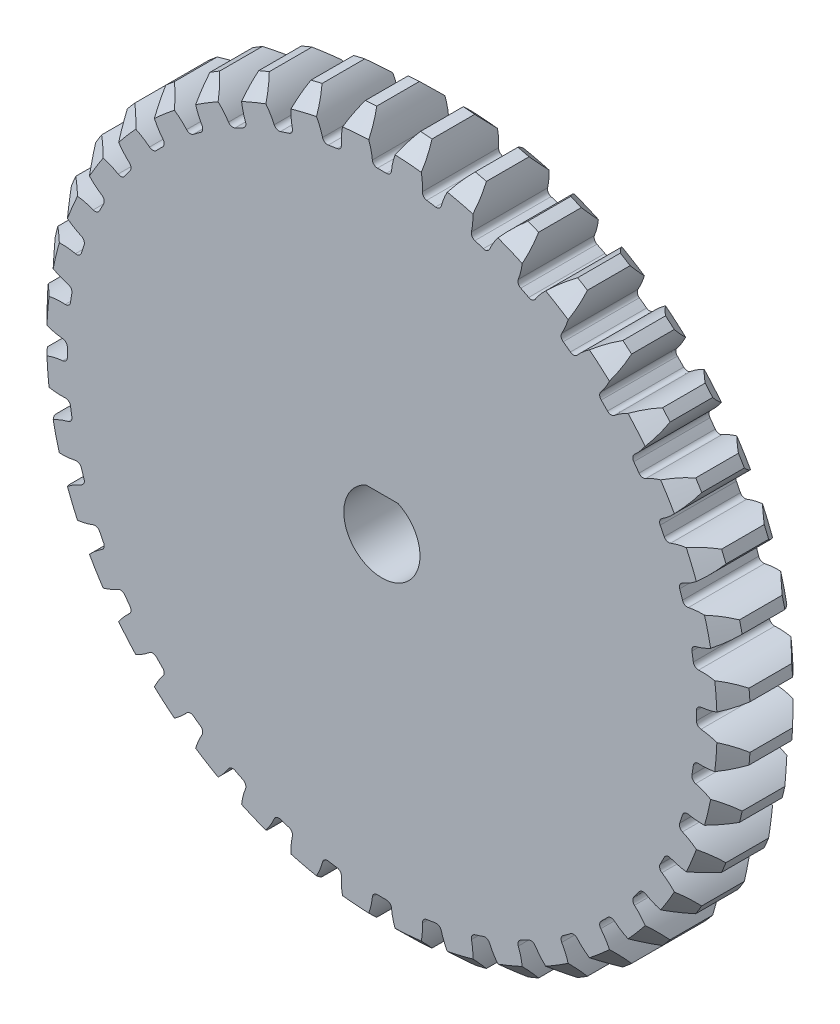
from build123d import *

# Parameters (mm, degrees)
SKETCH1_R                = 46.2
BOSS_EXTRUDE1_DEPTH      = 5
CUT_EXTRUDE1_DEPTH       = 66.527704065
FILLET1_R                = 0.66
CHAMFER1_SIZE            = 2.2
CIRPATTERN1_COUNT        = 40
FILLET1_OF_CIRPATTERN1_R = 0.66
CUT_EXTRUDE2_DEPTH       = 66.972376168
FILLET2_R                = 0.2
BOSS_EXTRUDE2_START      = -10
SKETCH5_R                = 10
BOSS_EXTRUDE2_DEPTH      = 19
SKETCH6_R                = 1.15
CUT_EXTRUDE3_DEPTH       = 67.695985001


with BuildPart() as part:
    # Sketch1 → Boss-Extrude1 (new, symmetric)
    with BuildSketch(Plane.XY):
        Circle(SKETCH1_R)
    extrude(amount=BOSS_EXTRUDE1_DEPTH, both=True)

    # Sketch2 → Cut-Extrude1 (cut, symmetric)
    with BuildSketch(Plane.XY):
        with BuildLine():
            ThreePointArc((2.874508928, 46.110489028), (1.67667641, 43.822688054), (1.213419035, 41.282170658))
            ThreePointArc((1.213419035, 41.282170658), (0, 41.3), (-1.213419035, 41.282170658))
            ThreePointArc((-1.213419035, 41.282170658), (-1.67667641, 43.822688054), (-2.874508928, 46.110489028))
            ThreePointArc((-2.874508928, 46.110489028), (0, 46.2), (2.874508928, 46.110489028))
        make_face()
    cut_extrude1 = extrude(amount=CUT_EXTRUDE1_DEPTH, both=True, mode=Mode.SUBTRACT)

    # Fillet1
    fillet1_edges = [part.edges().sort_by_distance(p)[0] for p in [
        (1.213419035, 41.282170658, 0),
        (-1.213419035, 41.282170658, 0),
    ]]
    fillet(fillet1_edges, radius=FILLET1_R)

    # Chamfer1
    chamfer1_edges = [part.edges().sort_by_distance(p)[0] for p in [
        (-31.635721009, -33.669290997, -5),
        (-31.635721009, -33.669290997, 5),
    ]]
    chamfer(chamfer1_edges, length=CHAMFER1_SIZE)

    # CirPattern1: Cut-Extrude1 ×40 about axis
    cirpattern1_axis = Axis((0, 0, 0), (0, 0, 1))
    for i in range(1, CIRPATTERN1_COUNT):
        add(cut_extrude1.rotate(cirpattern1_axis, i * 360 / CIRPATTERN1_COUNT), mode=Mode.SUBTRACT)

    # Fillet1 of CirPattern1
    fillet1_of_cirpattern1_edges = [part.edges().sort_by_distance(p)[0] for p in [
        (-5.25947445, 40.963739191, 0),
        (-7.656434116, 40.584098076, 0),
        (-11.602862218, 39.636644514, 0),
        (-13.910922378, 38.886710308, 0),
        (-17.660549011, 37.333564103, 0),
        (-19.822877564, 36.231802675, 0),
        (-23.283374475, 34.111207441, 0),
        (-25.246727716, 32.684747814, 0),
        (-28.332885987, 30.048919642, 0),
        (-30.048919642, 28.332885987, 0),
        (-32.684747814, 25.246727716, 0),
        (-34.111207441, 23.283374475, 0),
        (-36.231802675, 19.822877564, 0),
        (-37.333564103, 17.660549011, 0),
        (-38.886710308, 13.910922378, 0),
        (-39.636644514, 11.602862218, 0),
        (-40.584098076, 7.656434116, 0),
        (-40.963739191, 5.25947445, 0),
        (-41.282170658, 1.213419035, 0),
        (-41.282170658, -1.213419035, 0),
        (-40.963739191, -5.25947445, 0),
        (-40.584098076, -7.656434116, 0),
        (-39.636644514, -11.602862218, 0),
        (-38.886710308, -13.910922378, 0),
        (-37.333564103, -17.660549011, 0),
        (-36.231802675, -19.822877564, 0),
        (-34.111207441, -23.283374475, 0),
        (-32.684747814, -25.246727716, 0),
        (-30.048919642, -28.332885987, 0),
        (-28.332885987, -30.048919642, 0),
        (-25.246727716, -32.684747814, 0),
        (-23.283374475, -34.111207441, 0),
        (-19.822877564, -36.231802675, 0),
        (-17.660549011, -37.333564103, 0),
        (-13.910922378, -38.886710308, 0),
        (-11.602862218, -39.636644514, 0),
        (-7.656434116, -40.584098076, 0),
        (-5.25947445, -40.963739191, 0),
        (-1.213419035, -41.282170658, 0),
        (1.213419035, -41.282170658, 0),
        (5.25947445, -40.963739191, 0),
        (7.656434116, -40.584098076, 0),
        (11.602862218, -39.636644514, 0),
        (13.910922378, -38.886710308, 0),
        (17.660549011, -37.333564103, 0),
        (19.822877564, -36.231802675, 0),
        (23.283374475, -34.111207441, 0),
        (25.246727716, -32.684747814, 0),
        (28.332885987, -30.048919642, 0),
        (30.048919642, -28.332885987, 0),
        (32.684747814, -25.246727716, 0),
        (34.111207441, -23.283374475, 0),
        (36.231802675, -19.822877564, 0),
        (37.333564103, -17.660549011, 0),
        (38.886710308, -13.910922378, 0),
        (39.636644514, -11.602862218, 0),
        (40.584098076, -7.656434116, 0),
        (40.963739191, -5.25947445, 0),
        (41.282170658, -1.213419035, 0),
        (41.282170658, 1.213419035, 0),
        (40.963739191, 5.25947445, 0),
        (40.584098076, 7.656434116, 0),
        (39.636644514, 11.602862218, 0),
        (38.886710308, 13.910922378, 0),
        (37.333564103, 17.660549011, 0),
        (36.231802675, 19.822877564, 0),
        (34.111207441, 23.283374475, 0),
        (32.684747814, 25.246727716, 0),
        (30.048919642, 28.332885987, 0),
        (28.332885987, 30.048919642, 0),
        (25.246727716, 32.684747814, 0),
        (23.283374475, 34.111207441, 0),
        (19.822877564, 36.231802675, 0),
        (17.660549011, 37.333564103, 0),
        (13.910922378, 38.886710308, 0),
        (11.602862218, 39.636644514, 0),
        (7.656434116, 40.584098076, 0),
        (5.25947445, 40.963739191, 0),
    ]]
    fillet(fillet1_of_cirpattern1_edges, radius=FILLET1_OF_CIRPATTERN1_R)

    # Sketch3 → Cut-Extrude2 (cut, through all)
    with BuildSketch(Plane.XY.offset(5)):
        with BuildLine():
            Line((-2, 4.582575695), (-2, 7))
            Line((-2, 7), (2, 7))
            Line((2, 7), (2, 4.582575695))
            ThreePointArc((2, 4.582575695), (0, -5), (-2, 4.582575695))
        make_face()
    extrude(amount=-CUT_EXTRUDE2_DEPTH, mode=Mode.SUBTRACT)

    # Fillet2
    fillet2_edges = [part.edges().sort_by_distance(p)[0] for p in [
        (0, -5, -5),
        (2, 4.582575695, 0),
        (-2, 5.791287847, -5),
        (-2, 4.582575695, 0),
        (0, 7, -5),
        (-2, 7, 0),
        (2, 5.791287847, -5),
        (2, 7, 0),
        (0, -5, 5),
        (2, 5.791287847, 5),
        (0, 7, 5),
        (-2, 5.791287847, 5),
    ]]
    fillet(fillet2_edges, radius=FILLET2_R)

    # Sketch5 → Boss-Extrude2 (add)
    with BuildSketch(Plane(origin=(0, 0, -5), x_dir=(-1, 0, 0), z_dir=(0, 0, -1)).offset(BOSS_EXTRUDE2_START)):
        Circle(SKETCH5_R)
        with BuildLine():
            Line((-2.115384615, 4.530468842), (2.115384615, 4.530468842))
            ThreePointArc((2.115384615, 4.530468842), (0, -5), (-2.115384615, 4.530468842))
        make_face(mode=Mode.SUBTRACT)
    extrude(amount=BOSS_EXTRUDE2_DEPTH)

    # Sketch6 → Cut-Extrude3 (cut, through all)
    with BuildSketch(Plane(origin=(0, 0, 0), x_dir=(1, 0, 0), z_dir=(0, 1, 0))):
        with Locations(Location((0, 10, 0), (0, 0, 90))):
            Circle(SKETCH6_R)
    extrude(amount=CUT_EXTRUDE3_DEPTH, mode=Mode.SUBTRACT)


solid = part.part
